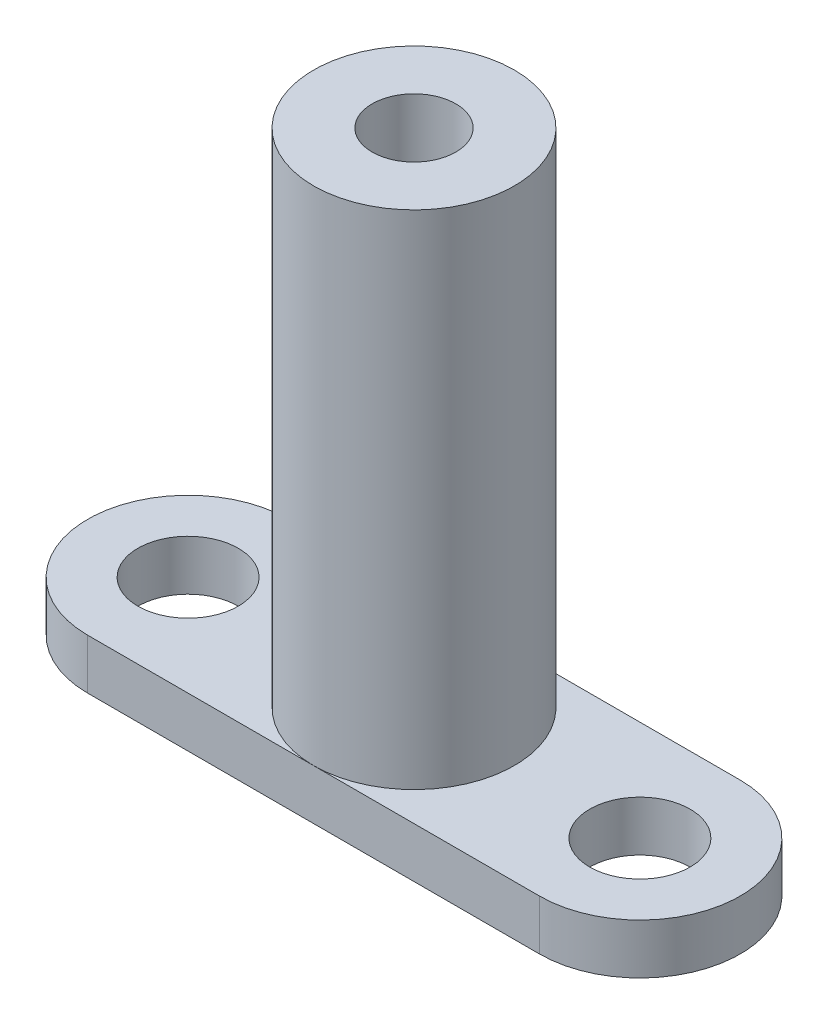
from build123d import *

# Parameters (mm, degrees)
SKETCH_1_R          = 6
EXTRUDE_1_DEPTH     = 3
SKETCH_2_R          = 6
EXTRUDE_2_DEPTH     = 30
HOLE_WIZARD_M6_1_D  = 5
SKETCH_6_R          = 3
CUT_EXTRUDE_1_DEPTH = 10


with BuildPart() as part:
    # 草图1 → 凸台-拉伸1 (new body)
    with BuildSketch(Plane(origin=(0, 0, 0), x_dir=(1, 0, 0), z_dir=(0, 1, 0))):
        with Locations((-13.5, 0)):
            Circle(SKETCH_1_R)
        with BuildLine():
            Line((13.5, 6), (-13.5, 6))
            ThreePointArc((-13.5, 6), (-9.257359313, 4.242640687), (-7.5, 0))
            ThreePointArc((-7.5, 0), (-9.257359313, -4.242640687), (-13.5, -6))
            Line((-13.5, -6), (13.5, -6))
            ThreePointArc((13.5, -6), (7.5, 0), (13.5, 6))
        make_face()
        with Locations((13.5, 0)):
            Circle(SKETCH_1_R)
    extrude(amount=EXTRUDE_1_DEPTH)

    # 草图2 → 凸台-拉伸2 (add)
    with BuildSketch(Plane(origin=(0, 3, 0), x_dir=(1, 0, 0), z_dir=(0, 1, 0))):
        Circle(SKETCH_2_R)
    extrude(amount=EXTRUDE_2_DEPTH)

    # M6 螺纹孔1 (through all)
    with Locations(Plane(origin=(0, 33, 0), x_dir=(1, 0, 0), z_dir=(0, 1, 0))):
        with Locations((0, 0)):
            Hole(HOLE_WIZARD_M6_1_D / 2)

    # 草图6 → 切除-拉伸1 (cut)
    with BuildSketch(Plane(origin=(0, 3, 0), x_dir=(1, 0, 0), z_dir=(0, 1, 0))):
        with Locations((-13.5, 0)):
            Circle(SKETCH_6_R)
        with Locations((13.5, 0)):
            Circle(SKETCH_6_R)
    extrude(amount=-CUT_EXTRUDE_1_DEPTH, mode=Mode.SUBTRACT)


solid = part.part
